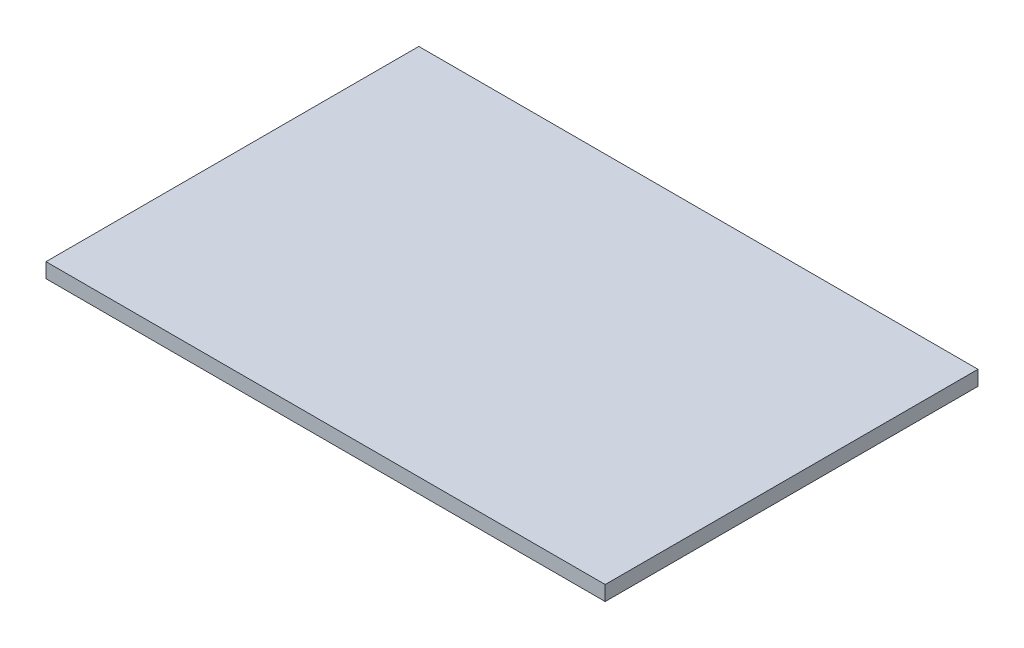
from build123d import *

# Parameters (mm, degrees)
SKETCH1_W           = 60
SKETCH1_H           = 40
BOSS_EXTRUDE1_DEPTH = 1.5875


with BuildPart() as part:
    # Sketch1 → Boss-Extrude1 (new body)
    with BuildSketch(Plane(origin=(0, 0, 0), x_dir=(1, 0, 0), z_dir=(0, 1, 0))):
        Rectangle(SKETCH1_W, SKETCH1_H)
    extrude(amount=BOSS_EXTRUDE1_DEPTH)


solid = part.part
